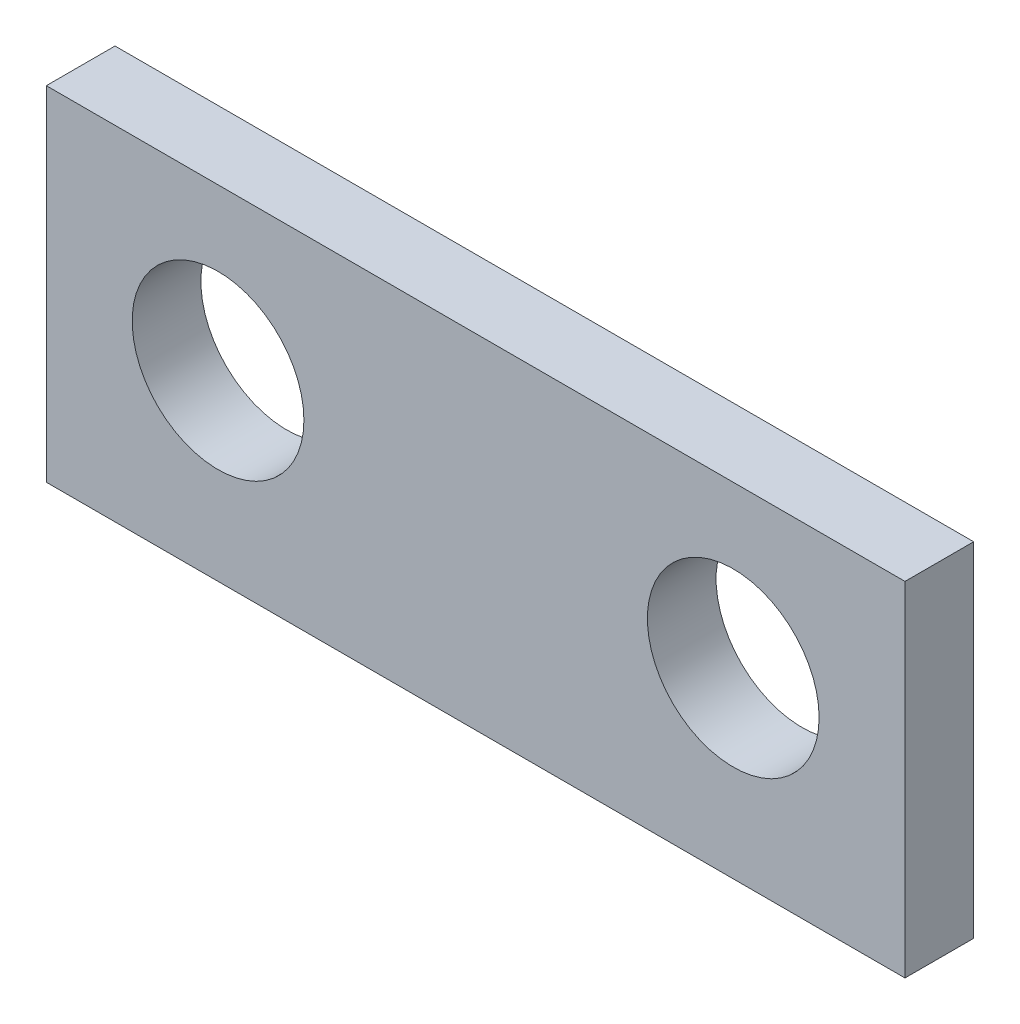
from build123d import *

# Parameters (mm, degrees)
SKETCH1_W           = 31.75
SKETCH1_H           = 12.7
SKETCH1_R           = 3.175
BOSS_EXTRUDE1_DEPTH = 2.54


with BuildPart() as part:
    # Sketch1 → Boss-Extrude1 (new body)
    with BuildSketch(Plane.XY):
        with Locations((15.875, 6.35)):
            Rectangle(SKETCH1_W, SKETCH1_H)
        with Locations((6.35, 6.753037648)):
            Circle(SKETCH1_R, mode=Mode.SUBTRACT)
        with Locations((25.4, 6.753037648)):
            Circle(SKETCH1_R, mode=Mode.SUBTRACT)
    extrude(amount=BOSS_EXTRUDE1_DEPTH)


solid = part.part
